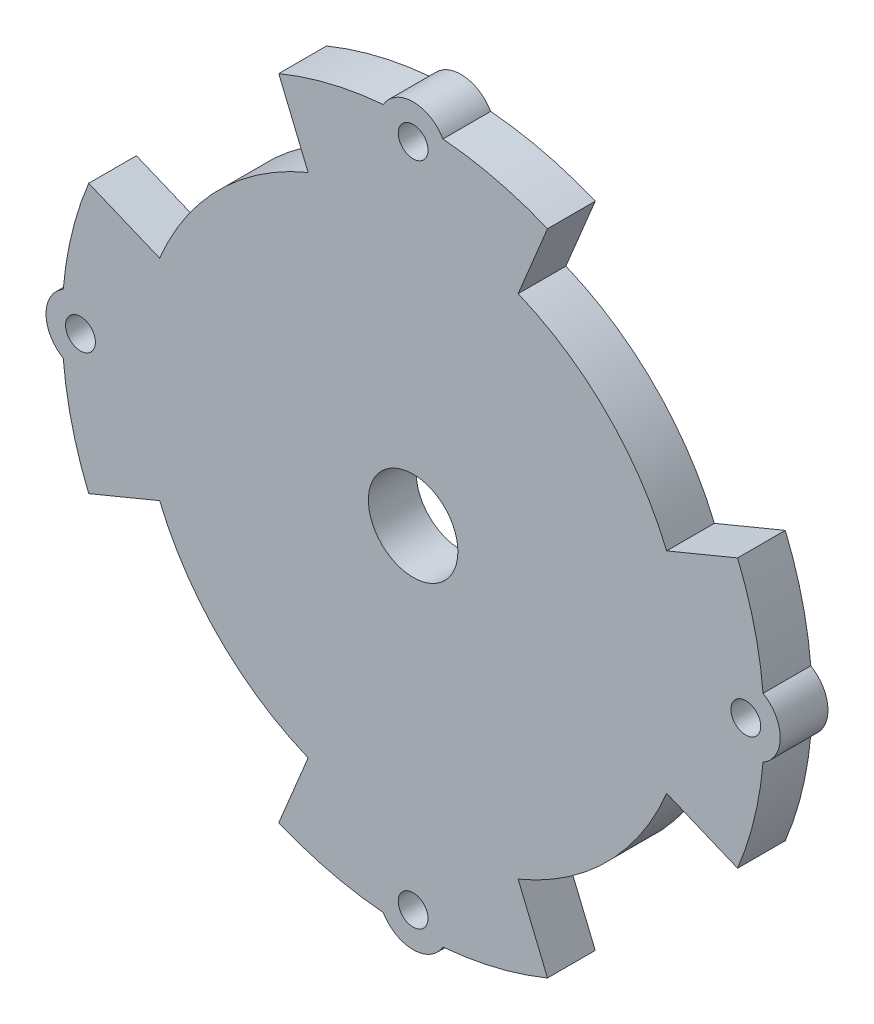
from build123d import *

# Parameters (mm, degrees)
SKETCH1_R           = 1.25
SKETCH1_R_2         = 3.75
BOSS_EXTRUDE2_DEPTH = 4


with BuildPart() as part:
    # Sketch1 → Boss-Extrude2 (new body)
    with BuildSketch(Plane.XY):
        with BuildLine():
            Line((-21.249229248, 8.801718944), (-27.195761321, 11.264853178))
            ThreePointArc((-27.195761321, 11.264853178), (-28.600693627, 6.964673358), (-29.330127019, 2.5))
            ThreePointArc((-29.330127019, 2.5), (-30.773502692, 0), (-29.330127019, -2.5))
            ThreePointArc((-29.330127019, -2.5), (-28.600693627, -6.964673358), (-27.195761321, -11.264853178))
            Line((-27.195761321, -11.264853178), (-21.249229248, -8.801718944))
            ThreePointArc((-21.249229248, -8.801718944), (-16.263455967, -16.263455967), (-8.801718944, -21.249229248))
            Line((-8.801718944, -21.249229248), (-11.264853178, -27.195761321))
            ThreePointArc((-11.264853178, -27.195761321), (-6.964673358, -28.600693627), (-2.5, -29.330127019))
            ThreePointArc((-2.5, -29.330127019), (0, -30.773502692), (2.5, -29.330127019))
            ThreePointArc((2.5, -29.330127019), (6.964673358, -28.600693627), (11.264853178, -27.195761321))
            Line((11.264853178, -27.195761321), (8.801718944, -21.249229248))
            ThreePointArc((8.801718944, -21.249229248), (16.263455967, -16.263455967), (21.249229248, -8.801718944))
            Line((21.249229248, -8.801718944), (27.195761321, -11.264853178))
            ThreePointArc((27.195761321, -11.264853178), (28.600693627, -6.964673358), (29.330127019, -2.5))
            ThreePointArc((29.330127019, -2.5), (30.773502692, 0), (29.330127019, 2.5))
            ThreePointArc((29.330127019, 2.5), (28.600693627, 6.964673358), (27.195761321, 11.264853178))
            Line((27.195761321, 11.264853178), (21.249229248, 8.801718944))
            ThreePointArc((21.249229248, 8.801718944), (16.263455967, 16.263455967), (8.801718944, 21.249229248))
            Line((8.801718944, 21.249229248), (11.264853178, 27.195761321))
            ThreePointArc((11.264853178, 27.195761321), (6.964673358, 28.600693627), (2.5, 29.330127019))
            ThreePointArc((2.5, 29.330127019), (0, 30.773502692), (-2.5, 29.330127019))
            ThreePointArc((-2.5, 29.330127019), (-6.964673358, 28.600693627), (-11.264853178, 27.195761321))
            Line((-11.264853178, 27.195761321), (-8.801718944, 21.249229248))
            ThreePointArc((-8.801718944, 21.249229248), (-16.263455967, 16.263455967), (-21.249229248, 8.801718944))
        make_face()
        with Locations((0, -27.886751346)):
            Circle(SKETCH1_R, mode=Mode.SUBTRACT)
        Circle(SKETCH1_R_2, mode=Mode.SUBTRACT)
        with Locations((27.886751346, 0)):
            Circle(SKETCH1_R, mode=Mode.SUBTRACT)
        with Locations((-27.886751346, 0)):
            Circle(SKETCH1_R, mode=Mode.SUBTRACT)
        with Locations((0, 27.886751346)):
            Circle(SKETCH1_R, mode=Mode.SUBTRACT)
    extrude(amount=BOSS_EXTRUDE2_DEPTH)


solid = part.part
